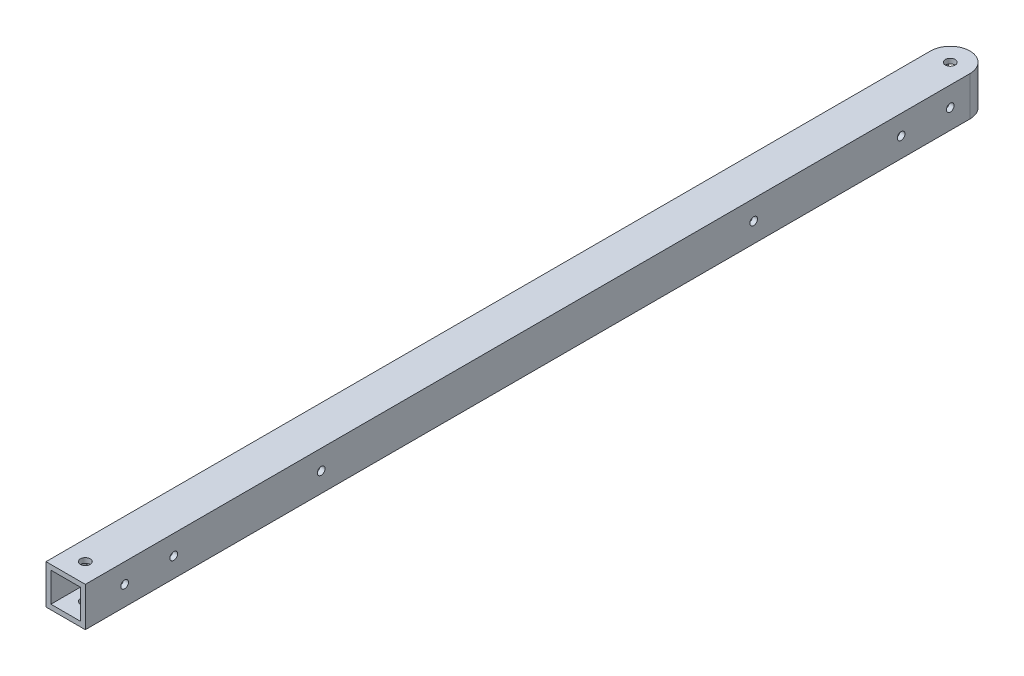
from build123d import *

# Parameters (mm, degrees)
SKETCH1_W           = 25.4
SKETCH1_H           = 25.4
SKETCH1_W_2         = 19.05
SKETCH1_H_2         = 19.05
EXTRUDE_THIN1_DEPTH = 292.1
SKETCH4_R           = 2.4892
CUT_EXTRUDE1_DEPTH  = 26.4
CUT_EXTRUDE2_DEPTH  = 26.4
SKETCH3_R           = 3.175
CUT_EXTRUDE3_DEPTH  = 26.4


with BuildPart() as part:
    # Sketch1 → Extrude-Thin1 (new body, symmetric)
    with BuildSketch(Plane.XY):
        Rectangle(SKETCH1_W, SKETCH1_H)
        Rectangle(SKETCH1_W_2, SKETCH1_H_2, mode=Mode.SUBTRACT)
    extrude(amount=EXTRUDE_THIN1_DEPTH, both=True)

    # Sketch4 → Cut-Extrude1 (cut, through all)
    with BuildSketch(Plane.ZY.offset(12.7)):
        with Locations((266.7, 0)):
            Circle(SKETCH4_R)
        with Locations((139.7, 0)):
            Circle(SKETCH4_R)
        with Locations((234.949999999, 0)):
            Circle(SKETCH4_R)
    cut_extrude1 = extrude(amount=-CUT_EXTRUDE1_DEPTH, mode=Mode.SUBTRACT)

    # Mirror1: Cut-Extrude1 across plane
    add(cut_extrude1.mirror(Plane(origin=(0, 0, 0), x_dir=(1, 0, 0), z_dir=(0, 0, -1))), mode=Mode.SUBTRACT)

    # Sketch5 → Cut-Extrude2 (cut, through all)
    with BuildSketch(Plane.XZ.offset(12.7)):
        Polygon((12.7, -298.45), (12.7, -292.1), (-6.7e-08, -292.1), (-12.7, -292.1), (-12.7, -298.45), align=None)
        with BuildLine():
            ThreePointArc((-6.7e-08, -292.1), (-8.980256145, -288.380256097), (-12.7, -279.4))
            Line((-12.7, -279.4), (-12.7, -292.1))
            Line((-12.7, -292.1), (-6.7e-08, -292.1))
        make_face()
        with BuildLine():
            Line((12.7, -292.1), (12.7, -279.4))
            ThreePointArc((12.7, -279.4), (8.980256097, -288.380256145), (-6.7e-08, -292.1))
            Line((-6.7e-08, -292.1), (12.7, -292.1))
        make_face()
    extrude(amount=-CUT_EXTRUDE2_DEPTH, mode=Mode.SUBTRACT)

    # Sketch3 → Cut-Extrude3 (cut, through all)
    with BuildSketch(Plane(origin=(0, 12.7, 0), x_dir=(1, 0, 0), z_dir=(0, 1, 0))):
        with Locations((0, 279.4)):
            Circle(SKETCH3_R)
        with Locations((0, -279.4)):
            Circle(SKETCH3_R)
    extrude(amount=-CUT_EXTRUDE3_DEPTH, mode=Mode.SUBTRACT)


solid = part.part
